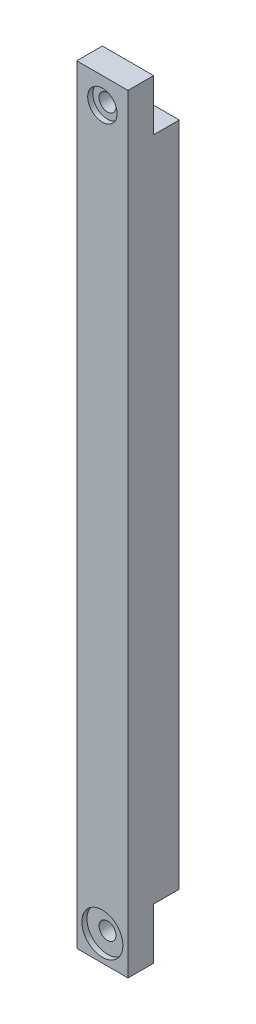
from build123d import *

# Parameters (mm, degrees)
SKETCH_1_W          = 10
SKETCH_1_H          = 150
EXTRUDE_1_DEPTH     = 10
SKETCH_3_W          = 10
SKETCH_3_H          = 10
CUT_EXTRUDE_1_DEPTH = 5
HOLE_WIZARD_M4_1_D  = 3.3
SKETCH_7_R          = 2.868052952
SKETCH_7_R_2        = 4
CUT_EXTRUDE_2_DEPTH = 1


with BuildPart() as part:
    # 草图1 → 凸台-拉伸1 (new body)
    with BuildSketch(Plane.XY):
        with Locations((5, -75)):
            Rectangle(SKETCH_1_W, SKETCH_1_H)
    extrude(amount=EXTRUDE_1_DEPTH)

    # 草图3 → 切除-拉伸1 (cut)
    with BuildSketch(Plane(origin=(0, 0, 0), x_dir=(-1, 0, 0), z_dir=(0, 0, -1))):
        with Locations((-5, -5)):
            Rectangle(SKETCH_3_W, SKETCH_3_H)
        with Locations((-5, -145)):
            Rectangle(SKETCH_3_W, SKETCH_3_H)
    extrude(amount=-CUT_EXTRUDE_1_DEPTH, mode=Mode.SUBTRACT)

    # M4 螺纹孔1 (through all)
    with Locations(Plane.XY.offset(10)):
        with Locations((5, -5), (5, -145)):
            Hole(HOLE_WIZARD_M4_1_D / 2)

    # 草图7 → 切除-拉伸2 (cut)
    with BuildSketch(Plane.XY.offset(10)):
        with Locations((5, -5)):
            Circle(SKETCH_7_R)
        with Locations((5, -145)):
            Circle(SKETCH_7_R_2)
    extrude(amount=-CUT_EXTRUDE_2_DEPTH, mode=Mode.SUBTRACT)


solid = part.part
